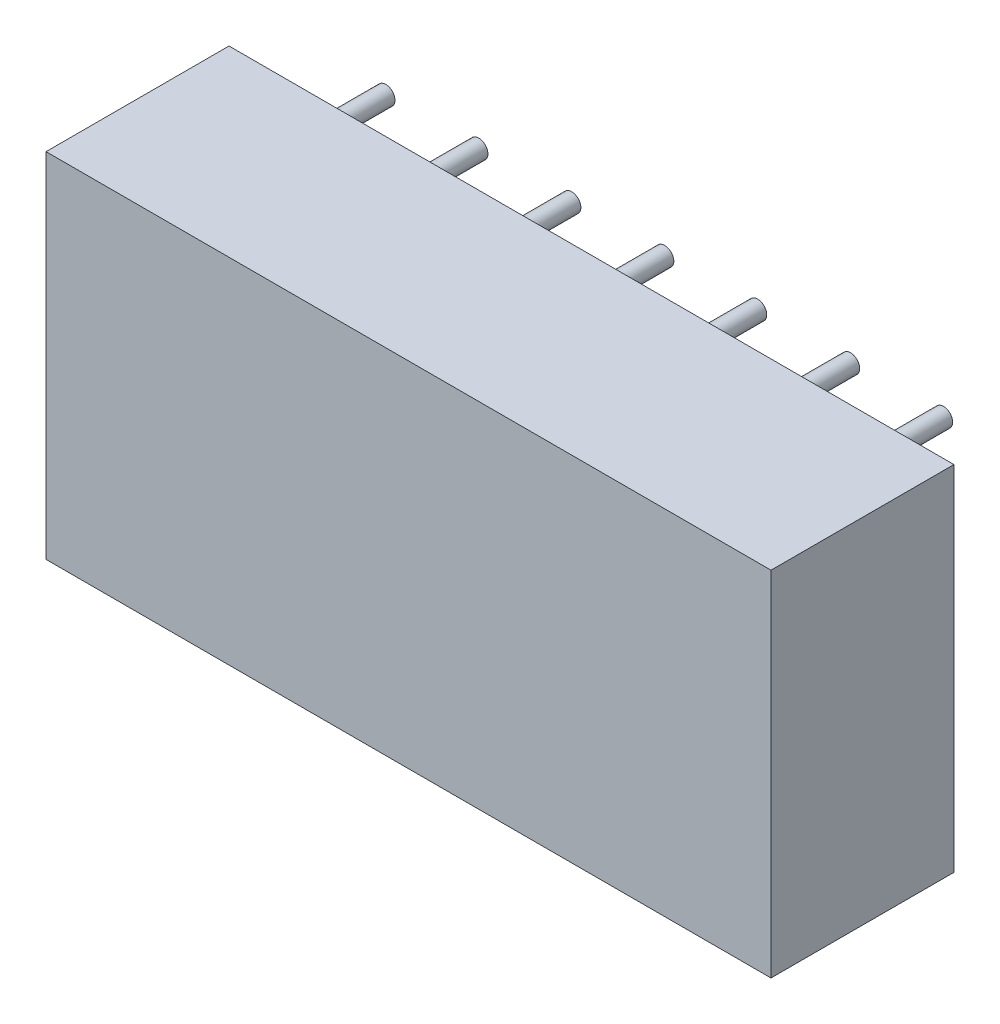
from build123d import *

# Parameters (mm, degrees)
SKETCH1_W               = 19.812
SKETCH1_H               = 9.652
COMPONENT_OUTLINE_DEPTH = 5
SKETCH2_R               = 0.25
EXTRUDE_1_DEPTH         = 2
SKETCH3_R               = 0.25
EXTRUDE_2_DEPTH         = 2
SKETCH4_R               = 0.25
EXTRUDE_3_DEPTH         = 2
SKETCH5_R               = 0.25
EXTRUDE_4_DEPTH         = 2
SKETCH6_R               = 0.25
EXTRUDE_5_DEPTH         = 2
SKETCH7_R               = 0.25
EXTRUDE_6_DEPTH         = 2
SKETCH8_R               = 0.25
EXTRUDE_7_DEPTH         = 2
SKETCH9_R               = 0.25
EXTRUDE_8_DEPTH         = 2
SKETCH10_R              = 0.25
EXTRUDE_9_DEPTH         = 2
SKETCH11_R              = 0.25
EXTRUDE_10_DEPTH        = 2
SKETCH12_R              = 0.25
EXTRUDE_11_DEPTH        = 2
SKETCH13_R              = 0.25
EXTRUDE_12_DEPTH        = 2
SKETCH14_R              = 0.25
EXTRUDE_13_DEPTH        = 2
SKETCH15_R              = 0.25
EXTRUDE_14_DEPTH        = 2


with BuildPart() as part:
    # Sketch1 → Component_Outline (new body)
    with BuildSketch(Plane.XY):
        with Locations((7.62, 3.81)):
            Rectangle(SKETCH1_W, SKETCH1_H)
    extrude(amount=COMPONENT_OUTLINE_DEPTH)


with BuildPart() as body_2:
    # Sketch2 → Extrude 1 (new body)
    with BuildSketch(Plane.XY):
        Circle(SKETCH2_R)
    extrude(amount=-EXTRUDE_1_DEPTH)


with BuildPart() as body_3:
    # Sketch3 → Extrude 2 (new body)
    with BuildSketch(Plane.XY):
        with Locations((2.54, 0)):
            Circle(SKETCH3_R)
    extrude(amount=-EXTRUDE_2_DEPTH)


with BuildPart() as body_4:
    # Sketch4 → Extrude 3 (new body)
    with BuildSketch(Plane.XY):
        with Locations((5.08, 0)):
            Circle(SKETCH4_R)
    extrude(amount=-EXTRUDE_3_DEPTH)


with BuildPart() as body_5:
    # Sketch5 → Extrude 4 (new body)
    with BuildSketch(Plane.XY):
        with Locations((7.62, 0)):
            Circle(SKETCH5_R)
    extrude(amount=-EXTRUDE_4_DEPTH)


with BuildPart() as body_6:
    # Sketch6 → Extrude 5 (new body)
    with BuildSketch(Plane.XY):
        with Locations((10.16, 0)):
            Circle(SKETCH6_R)
    extrude(amount=-EXTRUDE_5_DEPTH)


with BuildPart() as body_7:
    # Sketch7 → Extrude 6 (new body)
    with BuildSketch(Plane.XY):
        with Locations((12.7, 0)):
            Circle(SKETCH7_R)
    extrude(amount=-EXTRUDE_6_DEPTH)


with BuildPart() as body_8:
    # Sketch8 → Extrude 7 (new body)
    with BuildSketch(Plane.XY):
        with Locations((15.24, 0)):
            Circle(SKETCH8_R)
    extrude(amount=-EXTRUDE_7_DEPTH)


with BuildPart() as body_9:
    # Sketch9 → Extrude 8 (new body)
    with BuildSketch(Plane.XY):
        with Locations((15.24, 7.62)):
            Circle(SKETCH9_R)
    extrude(amount=-EXTRUDE_8_DEPTH)


with BuildPart() as body_10:
    # Sketch10 → Extrude 9 (new body)
    with BuildSketch(Plane.XY):
        with Locations((12.7, 7.62)):
            Circle(SKETCH10_R)
    extrude(amount=-EXTRUDE_9_DEPTH)


with BuildPart() as body_11:
    # Sketch11 → Extrude 10 (new body)
    with BuildSketch(Plane.XY):
        with Locations((10.16, 7.62)):
            Circle(SKETCH11_R)
    extrude(amount=-EXTRUDE_10_DEPTH)


with BuildPart() as body_12:
    # Sketch12 → Extrude 11 (new body)
    with BuildSketch(Plane.XY):
        with Locations((7.62, 7.62)):
            Circle(SKETCH12_R)
    extrude(amount=-EXTRUDE_11_DEPTH)


with BuildPart() as body_13:
    # Sketch13 → Extrude 12 (new body)
    with BuildSketch(Plane.XY):
        with Locations((5.08, 7.62)):
            Circle(SKETCH13_R)
    extrude(amount=-EXTRUDE_12_DEPTH)


with BuildPart() as body_14:
    # Sketch14 → Extrude 13 (new body)
    with BuildSketch(Plane.XY):
        with Locations((2.54, 7.62)):
            Circle(SKETCH14_R)
    extrude(amount=-EXTRUDE_13_DEPTH)


with BuildPart() as body_15:
    # Sketch15 → Extrude 14 (new body)
    with BuildSketch(Plane.XY):
        with Locations((0, 7.62)):
            Circle(SKETCH15_R)
    extrude(amount=-EXTRUDE_14_DEPTH)


solid = Compound([part.part, body_2.part, body_3.part, body_4.part, body_5.part, body_6.part, body_7.part, body_8.part, body_9.part, body_10.part, body_11.part, body_12.part, body_13.part, body_14.part, body_15.part])
